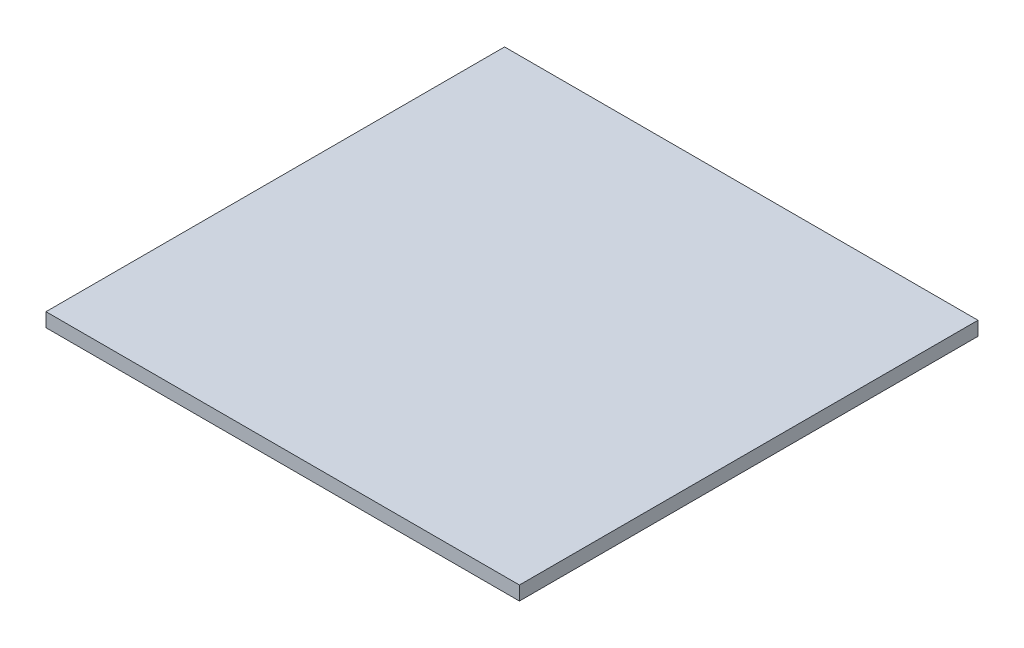
from build123d import *

# Parameters (mm, degrees)
SKETCH1_W           = 102
SKETCH1_H           = 98.8
BOSS_EXTRUDE1_DEPTH = 3


with BuildPart() as part:
    # Sketch1 → Boss-Extrude1 (new body)
    with BuildSketch(Plane(origin=(0, 0, 0), x_dir=(1, 0, 0), z_dir=(0, 1, 0))):
        with Locations((6.718457944, -28.701985981)):
            Rectangle(SKETCH1_W, SKETCH1_H)
    extrude(amount=BOSS_EXTRUDE1_DEPTH)


solid = part.part
